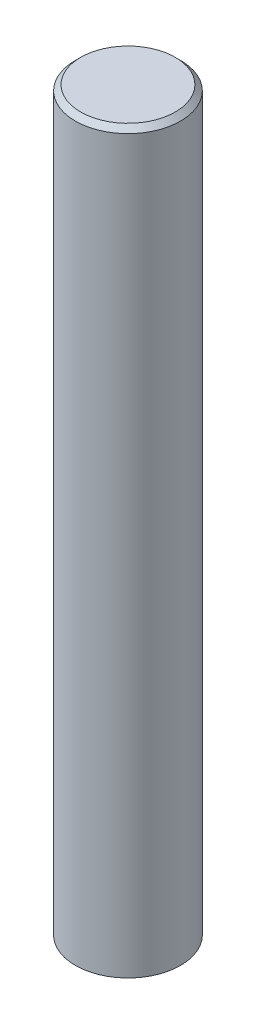
from build123d import *

# Parameters (mm, degrees)
SKETCH1_R           = 10
BOSS_EXTRUDE1_DEPTH = 140
CHAMFER1_SIZE       = 1


with BuildPart() as part:
    # Sketch1 → Boss-Extrude1 (new body)
    with BuildSketch(Plane(origin=(0, 0, 0), x_dir=(1, 0, 0), z_dir=(0, 1, 0))):
        Circle(SKETCH1_R)
    extrude(amount=BOSS_EXTRUDE1_DEPTH)

    # Chamfer1
    chamfer1_edges = [part.edges().sort_by_distance(p)[0] for p in [
        (-10, 140, 0),
    ]]
    chamfer(chamfer1_edges, length=CHAMFER1_SIZE)


solid = part.part
